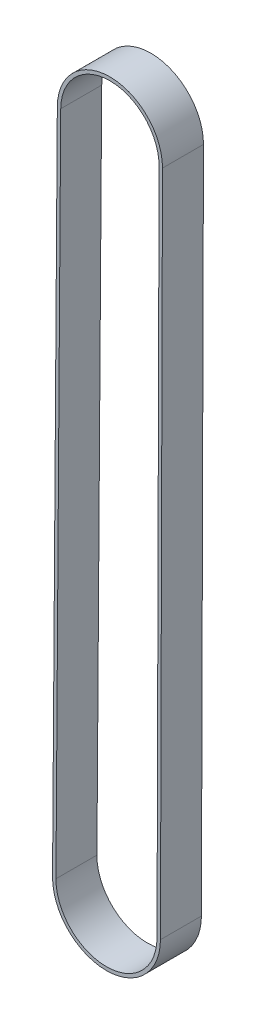
from build123d import *

# Parameters (mm, degrees)
EXTRUDE_THIN1_START = 0.25
EXTRUDE_THIN1_DEPTH = 6


with BuildPart() as part:
    # Sketch2 → Extrude-Thin1 (new body)
    with BuildSketch(Plane.XY.offset(EXTRUDE_THIN1_START)):
        with BuildLine():
            Line((-8.399798474, -100.743572457), (-7.699803576, -2.745001002))
            ThreePointArc((-7.699803576, -2.745001002), (0.039285203, 4.899899783), (7.699963922, -2.823571244))
            Line((7.699963922, -2.823571244), (7.399962985, -100.824183485))
            ThreePointArc((7.399962985, -100.824183485), (-0.540305598, -108.69989718), (-8.399798474, -100.743572457))
        make_face()
        with BuildLine():
            Line((-7.899811229, -100.74714382), (-7.199816331, -2.748572366))
            ThreePointArc((-7.199816331, -2.748572366), (0.036734216, 4.399906291), (7.199966265, -2.822040644))
            Line((7.199966265, -2.822040644), (6.899965327, -100.822652884))
            ThreePointArc((6.899965327, -100.822652884), (-0.537754611, -108.199903688), (-7.899811229, -100.74714382))
        make_face(mode=Mode.SUBTRACT)
    extrude(amount=EXTRUDE_THIN1_DEPTH)


solid = part.part
